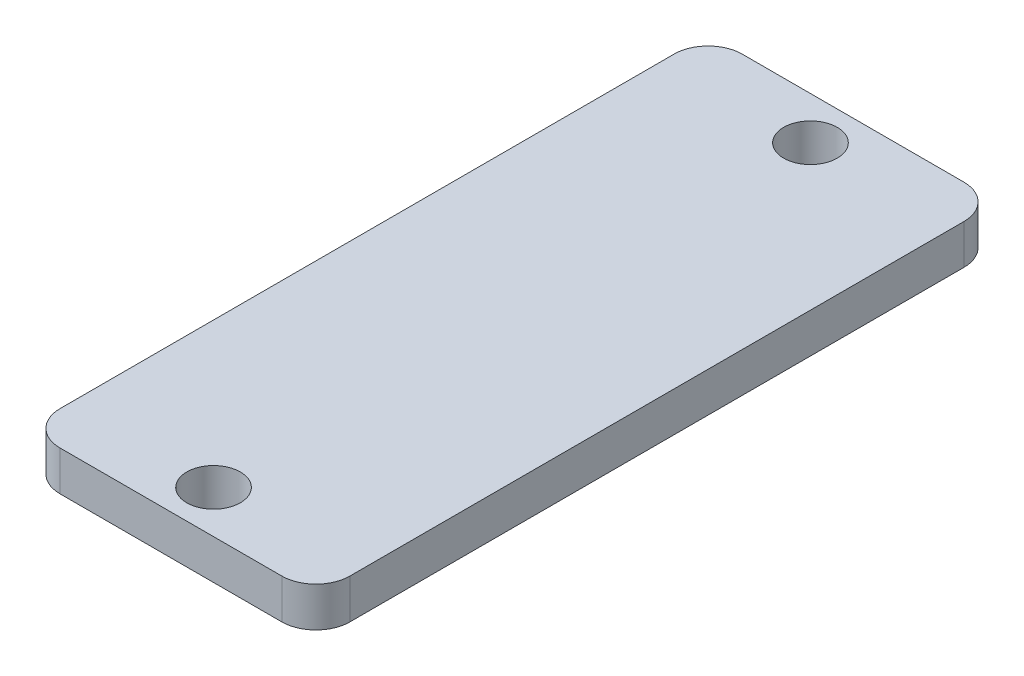
from build123d import *

# Parameters (mm, degrees)
SKETCH1_W           = 21.59
SKETCH1_H           = 50.8
SKETCH1_R           = 1.9939
BOSS_EXTRUDE1_DEPTH = 2.9591
FILLET1_R           = 2.54


with BuildPart() as part:
    # Sketch1 → Boss-Extrude1 (new body)
    with BuildSketch(Plane(origin=(0, 0, 0), x_dir=(1, 0, 0), z_dir=(0, 1, 0))):
        Rectangle(SKETCH1_W, SKETCH1_H)
        with Locations((0, 22.225)):
            Circle(SKETCH1_R, mode=Mode.SUBTRACT)
        with Locations((0, -22.225)):
            Circle(SKETCH1_R, mode=Mode.SUBTRACT)
    extrude(amount=BOSS_EXTRUDE1_DEPTH)

    # Fillet1
    fillet1_edges = [part.edges().sort_by_distance(p)[0] for p in [
        (10.795, 1.47955, 25.4),
        (-10.795, 1.47955, 25.4),
        (-10.795, 1.47955, -25.4),
        (10.795, 1.47955, -25.4),
    ]]
    fillet(fillet1_edges, radius=FILLET1_R)


solid = part.part
